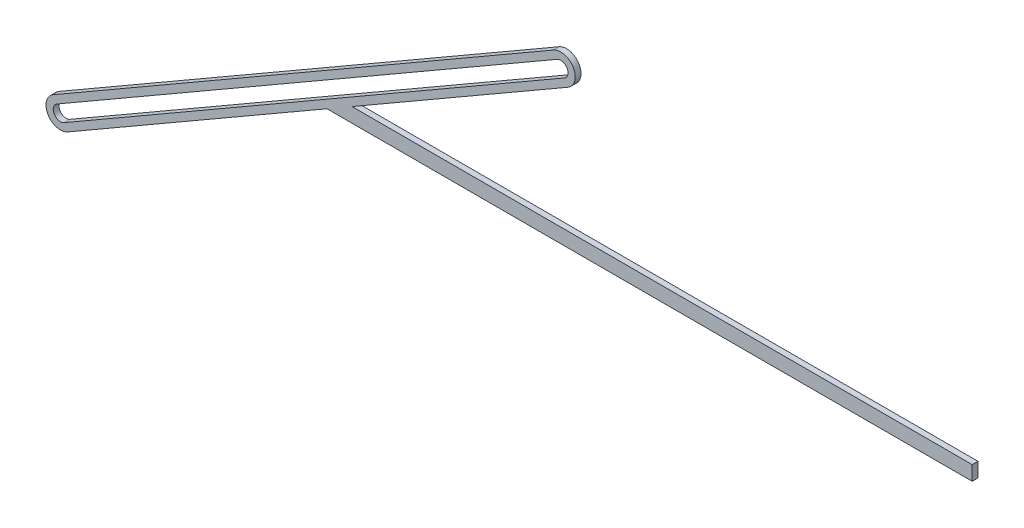
from build123d import *

# Parameters (mm, degrees)
EXTRUDE_1_DEPTH = 4


with BuildPart() as part:
    # 草图1 → 凸台-拉伸1 (new body)
    with BuildSketch(Plane.XY):
        with BuildLine():
            Line((-196.671823256, 5), (-47.126996537, 91.339745962))
            ThreePointArc((-47.126996537, 91.339745962), (-43.466742499, 105), (-57.126996537, 108.660254038))
            Line((-57.126996537, 108.660254038), (-403.537158051, -91.339745962))
            ThreePointArc((-403.537158051, -91.339745962), (-407.197412089, -105), (-393.537158051, -108.660254038))
            Line((-393.537158051, -108.660254038), (-213.992331332, -5))
            Line((-213.992331332, -5), (84.039471365, -5))
            Line((84.039471365, -5), (162.432840625, -5))
            Line((162.432840625, -5), (232.716639262, -5))
            Line((232.716639262, -5), (232.716639262, 5))
            Line((232.716639262, 5), (162.432840625, 5))
            Line((162.432840625, 5), (84.039471365, 5))
            Line((84.039471365, 5), (-196.671823256, 5))
        make_face()
        with BuildLine():
            Line((-401.037158051, -95.669872981), (-54.626996537, 104.330127019))
            ThreePointArc((-54.626996537, 104.330127019), (-47.796869518, 102.5), (-49.626996537, 95.669872981))
            Line((-49.626996537, 95.669872981), (-396.037158051, -104.330127019))
            ThreePointArc((-396.037158051, -104.330127019), (-402.86728507, -102.5), (-401.037158051, -95.669872981))
        make_face(mode=Mode.SUBTRACT)
    extrude(amount=EXTRUDE_1_DEPTH)


solid = part.part
